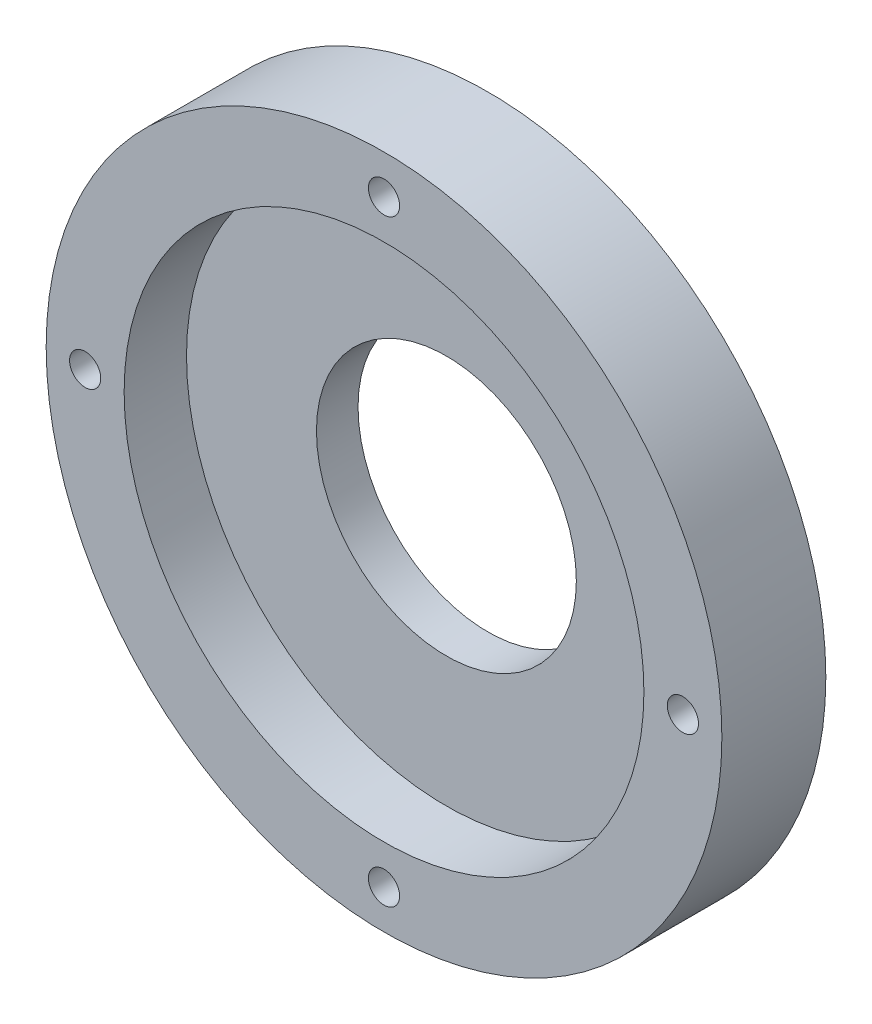
from build123d import *

# Parameters (mm, degrees)
ESQUISSE1_R             = 32.5
BOSS_EXTRU_1_DEPTH      = 4
ESQUISSE2_R             = 32.5
ESQUISSE2_R_2           = 25
BOSS_EXTRU_2_DEPTH      = 6
ESQUISSE3_R             = 1.5
ENL_V_MAT_EXTRU_1_DEPTH = 11
ESQUISSE4_R             = 12.5
ENL_V_MAT_EXTRU_2_DEPTH = 6


with BuildPart() as part:
    # Esquisse1 → Boss.-Extru.1 (new body)
    with BuildSketch(Plane.XY):
        Circle(ESQUISSE1_R)
    extrude(amount=BOSS_EXTRU_1_DEPTH)

    # Esquisse2 → Boss.-Extru.2 (add)
    with BuildSketch(Plane.XY.offset(4)):
        Circle(ESQUISSE2_R)
        Circle(ESQUISSE2_R_2, mode=Mode.SUBTRACT)
    extrude(amount=BOSS_EXTRU_2_DEPTH)

    # Esquisse3 → Enlèv. mat.-Extru.1 (cut, through all)
    with BuildSketch(Plane.XY.offset(10)):
        with Locations((0, 28.75)):
            Circle(ESQUISSE3_R)
        with Locations((28.75, 0)):
            Circle(ESQUISSE3_R)
        with Locations((0, -28.75)):
            Circle(ESQUISSE3_R)
        with Locations((-28.75, 0)):
            Circle(ESQUISSE3_R)
    extrude(amount=-ENL_V_MAT_EXTRU_1_DEPTH, mode=Mode.SUBTRACT)

    # Esquisse4 → Enlèv. mat.-Extru.2 (cut)
    with BuildSketch(Plane(origin=(0, 0, 0), x_dir=(-1, 0, 0), z_dir=(0, 0, -1))):
        Circle(ESQUISSE4_R)
    extrude(amount=-ENL_V_MAT_EXTRU_2_DEPTH, mode=Mode.SUBTRACT)


solid = part.part
